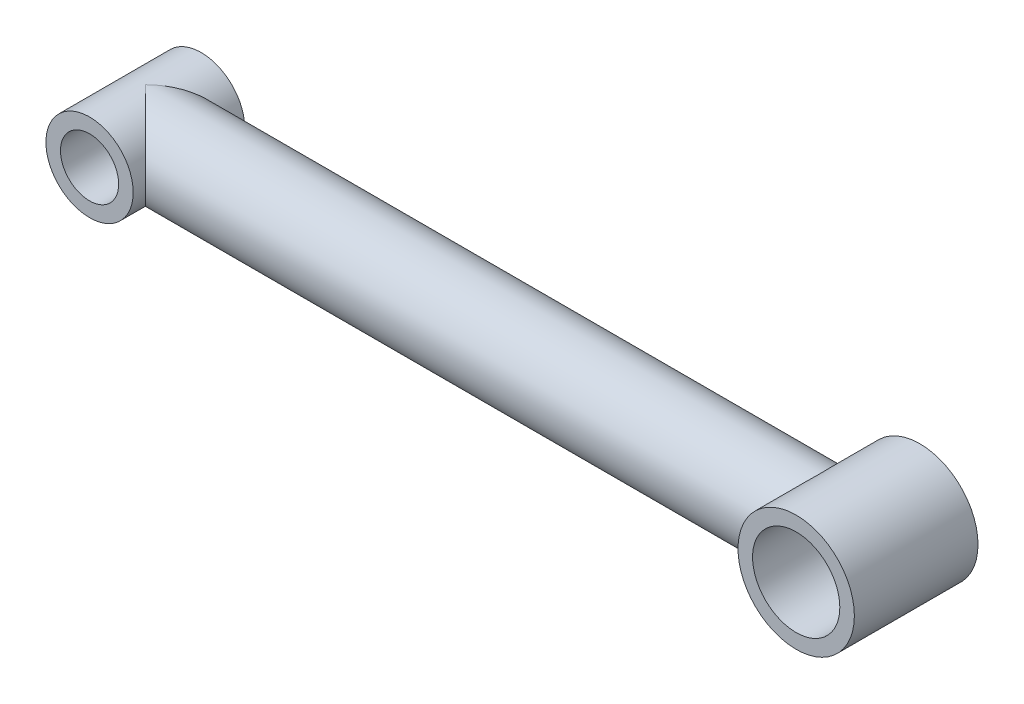
from build123d import *

# Parameters (mm, degrees)
BOSS_EXTRUDE1_DEPTH      = 39.51605
BOSS_EXTRUDE1_DEPTH_BACK = 39.51605
SKETCH1_R                = 4.8387
BOSS_EXTRUDE2_DEPTH      = 6.18871
BOSS_EXTRUDE2_DEPTH_BACK = 6.18871
SKETCH2_R                = 4.8387
SKETCH3_R                = 3.2258
CUT_EXTRUDE1_DEPTH       = 47.302887503
BOSS_EXTRUDE3_DEPTH      = 6.85546
BOSS_EXTRUDE3_DEPTH_BACK = 6.85546
SKETCH4_R                = 6.4516
SKETCH5_R                = 4.8387
CUT_EXTRUDE2_DEPTH       = 49.400798852


with BuildPart() as part:
    # Sketch1 → Boss-Extrude1 (new, two sides: drawn at the far end of the back side and taken through both)
    with BuildSketch(Plane(origin=(0, 0, 0), x_dir=(0, 0, -1), z_dir=(1, 0, 0)).offset(-BOSS_EXTRUDE1_DEPTH_BACK)):
        Circle(SKETCH1_R)
    extrude(amount=BOSS_EXTRUDE1_DEPTH + BOSS_EXTRUDE1_DEPTH_BACK)

    # Sketch2 → Boss-Extrude2 (add, two sides: drawn at the far end of the back side and taken through both)
    with BuildSketch(Plane.XY.offset(-BOSS_EXTRUDE2_DEPTH_BACK)):
        with Locations((-39.51605, 0)):
            Circle(SKETCH2_R)
    extrude(amount=BOSS_EXTRUDE2_DEPTH + BOSS_EXTRUDE2_DEPTH_BACK)

    # Sketch3 → Cut-Extrude1 (cut, through all)
    with BuildSketch(Plane.XY.offset(6.18871)):
        with Locations((-39.51605, 0)):
            Circle(SKETCH3_R)
    extrude(amount=-CUT_EXTRUDE1_DEPTH, mode=Mode.SUBTRACT)

    # Sketch4 → Boss-Extrude3 (add, two sides: drawn at the far end of the back side and taken through both)
    with BuildSketch(Plane.XY.offset(-BOSS_EXTRUDE3_DEPTH_BACK)):
        with Locations((39.51605, 0)):
            Circle(SKETCH4_R)
    extrude(amount=BOSS_EXTRUDE3_DEPTH + BOSS_EXTRUDE3_DEPTH_BACK)

    # Sketch5 → Cut-Extrude2 (cut, through all)
    with BuildSketch(Plane.XY.offset(6.85546)):
        with Locations((39.51605, 0)):
            Circle(SKETCH5_R)
    extrude(amount=-CUT_EXTRUDE2_DEPTH, mode=Mode.SUBTRACT)


solid = part.part
